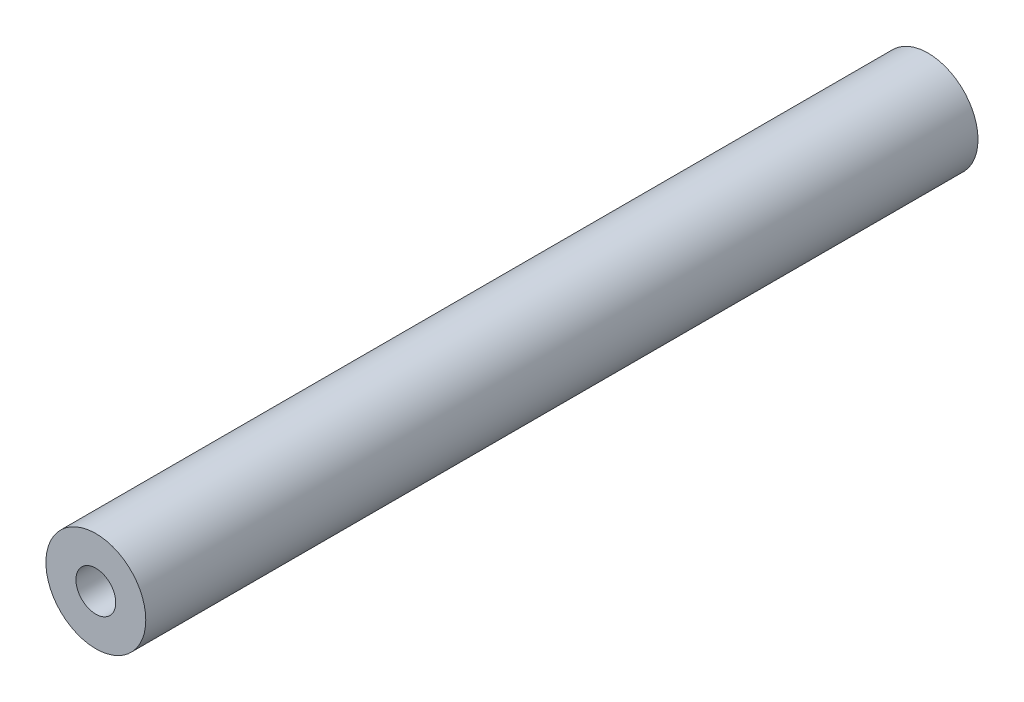
from build123d import *

# Parameters (mm, degrees)
SKETCH1_R           = 4.7625
BOSS_EXTRUDE1_DEPTH = 79.375
SKETCH2_R           = 1.89865
CUT_EXTRUDE1_DEPTH  = 25.4
SKETCH3_R           = 1.89865
CUT_EXTRUDE2_DEPTH  = 25.4


with BuildPart() as part:
    # Sketch1 → Boss-Extrude1 (new body)
    with BuildSketch(Plane.XY):
        Circle(SKETCH1_R)
    extrude(amount=BOSS_EXTRUDE1_DEPTH)

    # Sketch2 → Cut-Extrude1 (cut)
    with BuildSketch(Plane.XY.offset(79.375)):
        Circle(SKETCH2_R)
    extrude(amount=-CUT_EXTRUDE1_DEPTH, mode=Mode.SUBTRACT)

    # Sketch3 → Cut-Extrude2 (cut)
    with BuildSketch(Plane(origin=(0, 0, 0), x_dir=(-1, 0, 0), z_dir=(0, 0, -1))):
        Circle(SKETCH3_R)
    extrude(amount=-CUT_EXTRUDE2_DEPTH, mode=Mode.SUBTRACT)


solid = part.part
